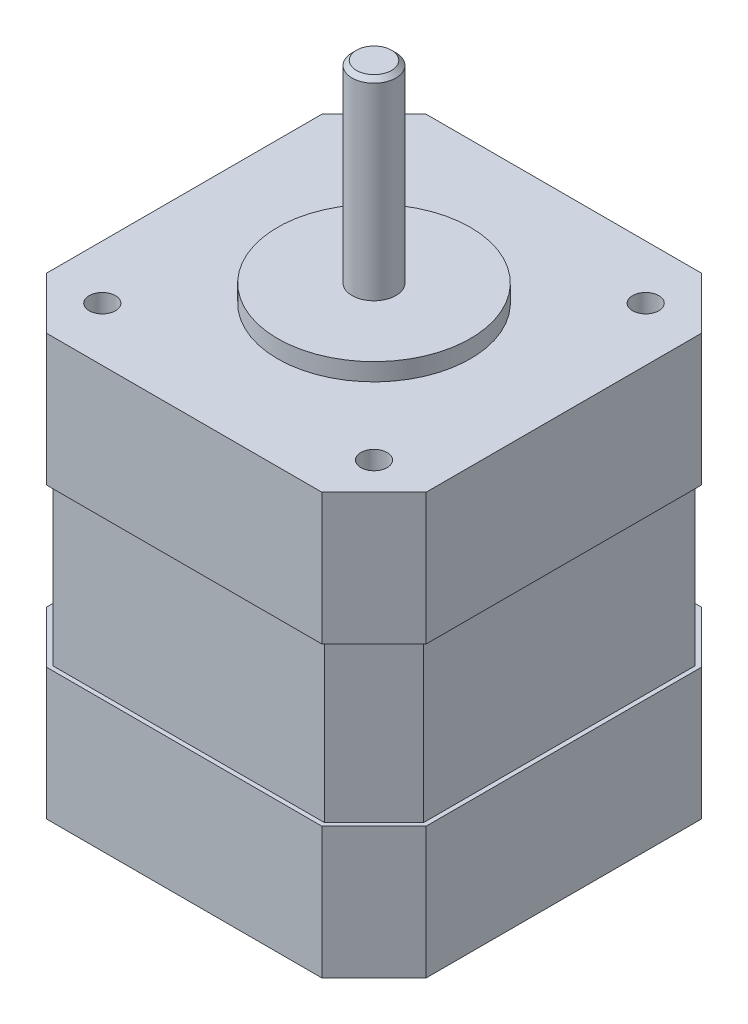
from build123d import *

# Parameters (mm, degrees)
BOSS_EXTRUDE1_DEPTH = 48
SKETCH2_R           = 11
BOSS_EXTRUDE2_DEPTH = 2
SKETCH3_R           = 2.5
BOSS_EXTRUDE3_DEPTH = 22
CHAMFER1_SIZE       = 0.5
SKETCH4_R           = 1.5
CUT_EXTRUDE1_DEPTH  = 10
BOSS_EXTRUDE5_DEPTH = 15


with BuildPart() as part:
    # Sketch1 → Boss-Extrude1 (new body)
    with BuildSketch(Plane(origin=(0, 0, 0), x_dir=(1, 0, 0), z_dir=(0, 1, 0))):
        Polygon((15.5, 21.15), (21.15, 15.5), (21.15, -15.5), (15.5, -21.15), (-15.5, -21.15), (-21.15, -15.5), (-21.15, 15.5), (-15.5, 21.15), align=None)
    extrude(amount=BOSS_EXTRUDE1_DEPTH)

    # Sketch2 → Boss-Extrude2 (add)
    with BuildSketch(Plane(origin=(0, 48, 0), x_dir=(1, 0, 0), z_dir=(0, 1, 0))):
        Circle(SKETCH2_R)
    extrude(amount=BOSS_EXTRUDE2_DEPTH)

    # Sketch3 → Boss-Extrude3 (add)
    with BuildSketch(Plane(origin=(0, 50, 0), x_dir=(1, 0, 0), z_dir=(0, 1, 0))):
        Circle(SKETCH3_R)
    extrude(amount=BOSS_EXTRUDE3_DEPTH)

    # Chamfer1
    chamfer1_edges = [part.edges().sort_by_distance(p)[0] for p in [
        (-2.5, 72, 0),
    ]]
    chamfer(chamfer1_edges, length=CHAMFER1_SIZE)

    # Sketch4 → Cut-Extrude1 (cut)
    with BuildSketch(Plane(origin=(0, 48, 0), x_dir=(1, 0, 0), z_dir=(0, 1, 0))):
        with Locations((-15.5, 15.5)):
            Circle(SKETCH4_R)
        with Locations((15.5, 15.5)):
            Circle(SKETCH4_R)
        with Locations((15.5, -15.5)):
            Circle(SKETCH4_R)
        with Locations((-15.5, -15.5)):
            Circle(SKETCH4_R)
    extrude(amount=-CUT_EXTRUDE1_DEPTH, mode=Mode.SUBTRACT)

    # Sketch6 → Boss-Extrude5 (add)
    with BuildSketch(Plane(origin=(0, 48, 0), x_dir=(1, 0, 0), z_dir=(0, 1, 0))):
        Polygon((-21.65, -15.707106781), (-15.707106781, -21.65), (15.707106781, -21.65), (21.65, -15.707106781), (21.65, 15.707106781), (15.707106781, 21.65), (-15.707106781, 21.65), (-21.65, 15.707106781), align=None)
        Polygon((-21.15, -15.5), (-15.5, -21.15), (15.5, -21.15), (21.15, -15.5), (21.15, 15.5), (15.5, 21.15), (-15.5, 21.15), (-21.15, 15.5), align=None, mode=Mode.SUBTRACT)
    boss_extrude5 = extrude(amount=-BOSS_EXTRUDE5_DEPTH)

    # Mirror1: Boss-Extrude5 across plane
    add(boss_extrude5.mirror(Plane.ZX.offset(24)))


solid = part.part
